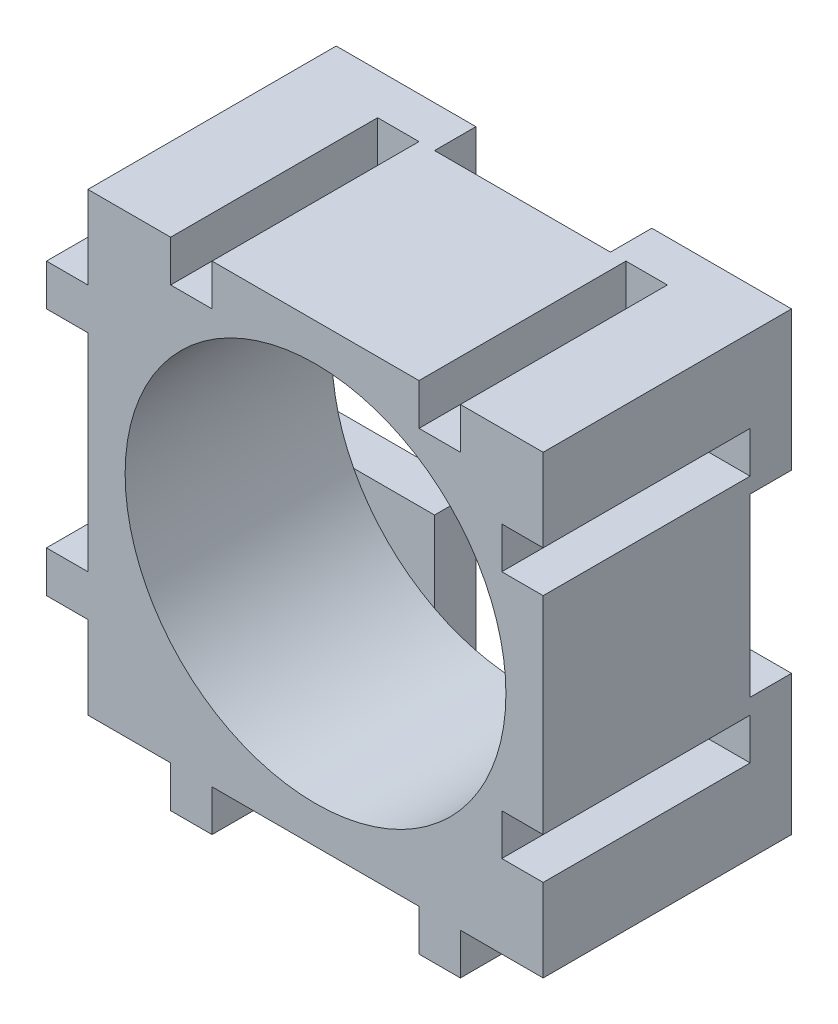
from build123d import *

# Parameters (mm, degrees)
SKETCH1_W           = 22
SKETCH1_H           = 22
BOSS_EXTRUDE1_DEPTH = 10
SKETCH3_W           = 2
SKETCH3_H           = 10
BOSS_EXTRUDE2_DEPTH = 2
SKETCH4_W           = 10
SKETCH4_H           = 2
BOSS_EXTRUDE3_DEPTH = 2
SKETCH5_W           = 10
SKETCH5_H           = 2
CUT_EXTRUDE1_DEPTH  = 2
SKETCH6_W           = 2
SKETCH6_H           = 10
CUT_EXTRUDE2_DEPTH  = 2
SKETCH7_R           = 9.2
CUT_EXTRUDE3_DEPTH  = 11
SKETCH8_W           = 6.75
SKETCH8_H           = 6.75
BOSS_EXTRUDE4_DEPTH = 2


with BuildPart() as part:
    # Sketch1 → Boss-Extrude1 (new body)
    with BuildSketch(Plane.XY):
        with Locations((1.600938967, -1.755868545)):
            Rectangle(SKETCH1_W, SKETCH1_H)
    extrude(amount=BOSS_EXTRUDE1_DEPTH)

    # Sketch3 → Boss-Extrude2 (add)
    with BuildSketch(Plane.XZ.offset(12.755868545)):
        with Locations((7.600938967, 5)):
            Rectangle(SKETCH3_W, SKETCH3_H)
        with Locations((-4.399061033, 5)):
            Rectangle(SKETCH3_W, SKETCH3_H)
    extrude(amount=BOSS_EXTRUDE2_DEPTH)

    # Sketch4 → Boss-Extrude3 (add)
    with BuildSketch(Plane.ZY.offset(9.399061033)):
        with Locations((5, 4.244131455)):
            Rectangle(SKETCH4_W, SKETCH4_H)
        with Locations((5, -7.755868545)):
            Rectangle(SKETCH4_W, SKETCH4_H)
    extrude(amount=BOSS_EXTRUDE3_DEPTH)

    # Sketch5 → Cut-Extrude1 (cut)
    with BuildSketch(Plane(origin=(12.600938967, 0, 0), x_dir=(0, 0, -1), z_dir=(1, 0, 0))):
        with Locations((-5, 4.244131455)):
            Rectangle(SKETCH5_W, SKETCH5_H)
        with Locations((-5, -7.755868545)):
            Rectangle(SKETCH5_W, SKETCH5_H)
    extrude(amount=-CUT_EXTRUDE1_DEPTH, mode=Mode.SUBTRACT)

    # Sketch6 → Cut-Extrude2 (cut)
    with BuildSketch(Plane(origin=(0, 9.244131455, 0), x_dir=(1, 0, 0), z_dir=(0, 1, 0))):
        with Locations((-4.399061033, -5)):
            Rectangle(SKETCH6_W, SKETCH6_H)
        with Locations((7.600938967, -5)):
            Rectangle(SKETCH6_W, SKETCH6_H)
    extrude(amount=-CUT_EXTRUDE2_DEPTH, mode=Mode.SUBTRACT)

    # Sketch7 → Cut-Extrude3 (cut, through all)
    with BuildSketch(Plane.XY.offset(10)):
        with Locations((1.600938967, -1.755868545)):
            Circle(SKETCH7_R)
    extrude(amount=-CUT_EXTRUDE3_DEPTH, mode=Mode.SUBTRACT)

    # Sketch8 → Boss-Extrude4 (add)
    with BuildSketch(Plane(origin=(0, 0, 0), x_dir=(-1, 0, 0), z_dir=(0, 0, -1))):
        with Locations((6.024061033, 5.869131455)):
            Rectangle(SKETCH8_W, SKETCH8_H)
        with Locations((-9.225938967, 5.869131455)):
            Rectangle(SKETCH8_W, SKETCH8_H)
        with Locations((-9.225938967, -9.380868545)):
            Rectangle(SKETCH8_W, SKETCH8_H)
        with Locations((6.024061033, -9.380868545)):
            Rectangle(SKETCH8_W, SKETCH8_H)
    extrude(amount=BOSS_EXTRUDE4_DEPTH)


solid = part.part
